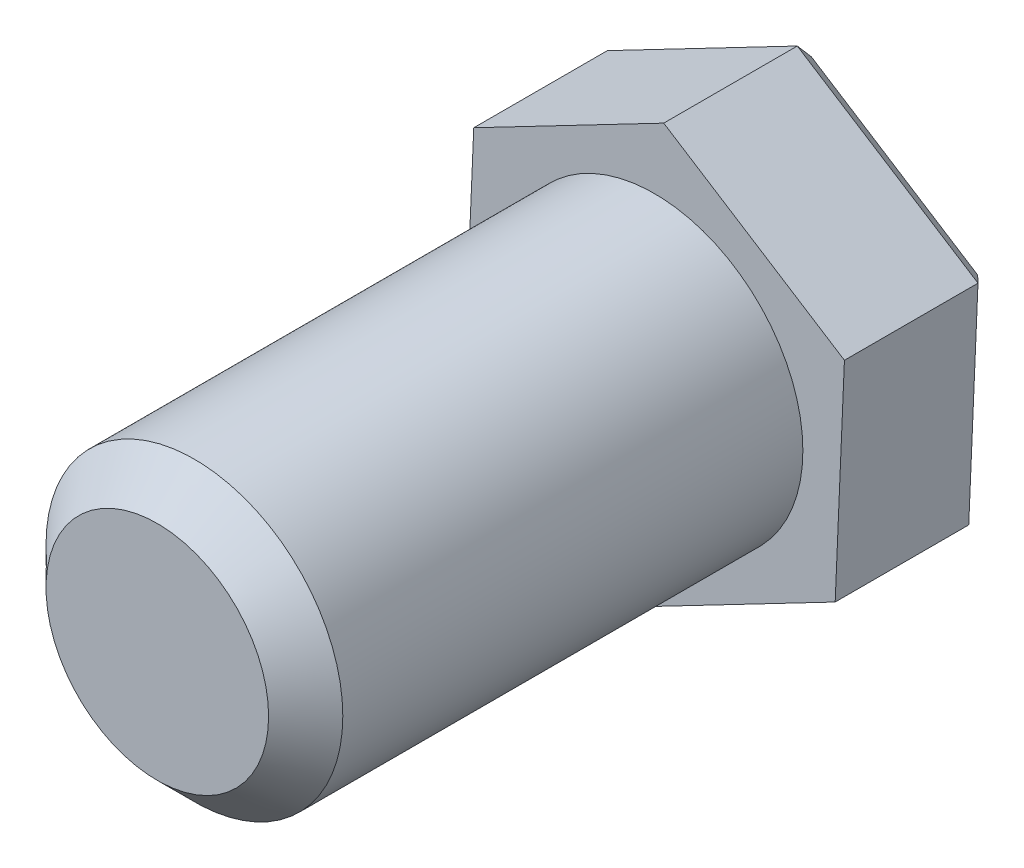
from build123d import *

# Parameters (mm, degrees)
SKETCH1_R           = 2
BOSS_EXTRUDE1_DEPTH = 6.7
CHAMFER1_SIZE       = 0.5
BOSS_EXTRUDE2_DEPTH = 2
CHAMFER2_SIZE       = 0.2


with BuildPart() as part:
    # Sketch1 → Boss-Extrude1 (new body)
    with BuildSketch(Plane.XY):
        Circle(SKETCH1_R)
    extrude(amount=BOSS_EXTRUDE1_DEPTH)

    # Chamfer1
    chamfer1_edges = [part.edges().sort_by_distance(p)[0] for p in [
        (-2, 0, 6.7),
    ]]
    chamfer(chamfer1_edges, length=CHAMFER1_SIZE)

    # Sketch2 → Boss-Extrude2 (add)
    with BuildSketch(Plane(origin=(0, 0, 0), x_dir=(-1, 0, 0), z_dir=(0, 0, -1))):
        Polygon((0.124813216, -2.884051836), (2.560068764, -1.333934502), (2.435255548, 1.550117334), (-0.124813216, 2.884051836), (-2.560068764, 1.333934502), (-2.435255548, -1.550117334), align=None)
    extrude(amount=BOSS_EXTRUDE2_DEPTH)

    # Chamfer2
    chamfer2_edges = [part.edges().sort_by_distance(p)[0] for p in [
        (1.155221166, -2.217084585, -2),
        (-1.34244099, -2.108993169, -2),
        (-2.497662156, 0.108091416, -2),
        (-1.155221166, 2.217084585, -2),
        (1.34244099, 2.108993169, -2),
        (2.497662156, -0.108091416, -2),
    ]]
    chamfer(chamfer2_edges, length=CHAMFER2_SIZE)


solid = part.part
